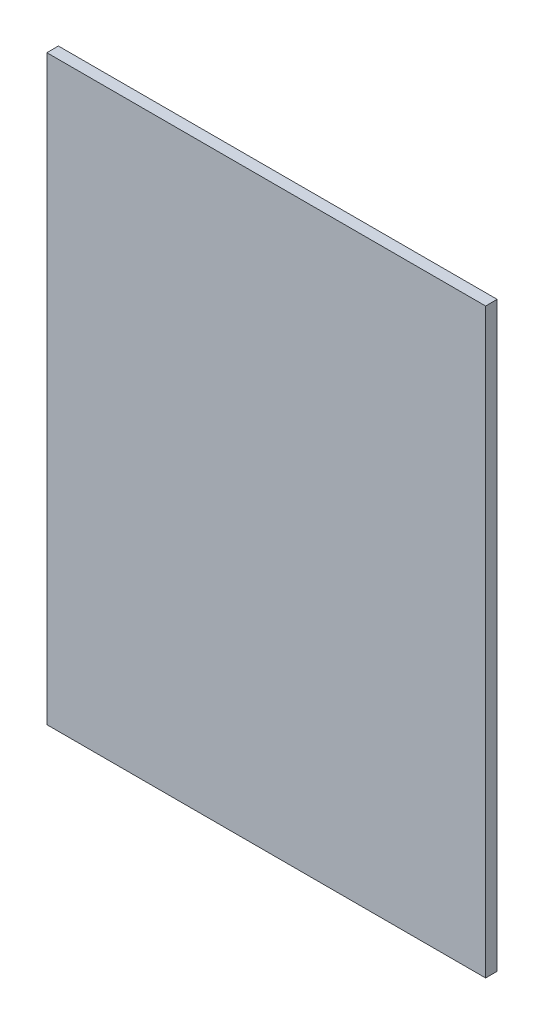
from build123d import *

# Parameters (mm, degrees)
ESQUISSE1_W        = 190
ESQUISSE1_H        = 252
BOSS_EXTRU_1_DEPTH = 5


with BuildPart() as part:
    # Esquisse1 → Boss.-Extru.1 (new body)
    with BuildSketch(Plane.XY):
        with Locations((225, -94.8)):
            Rectangle(ESQUISSE1_W, ESQUISSE1_H)
    extrude(amount=BOSS_EXTRU_1_DEPTH)


solid = part.part
